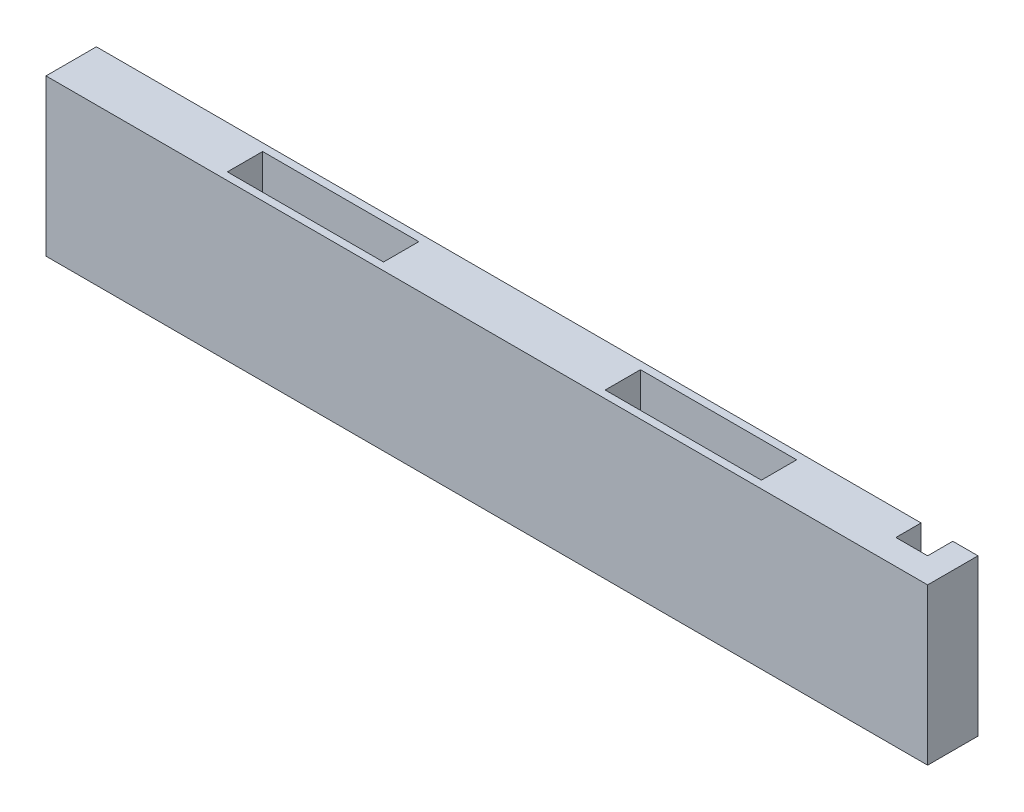
from build123d import *

# Parameters (mm, degrees)
ESBO_O1_W                = 175
ESBO_O1_H                = 31
RESSALTO_EXTRUS_O1_DEPTH = 10
ESBO_O2_W                = 31
ESBO_O2_H                = 7
CORTE_EXTRUS_O1_DEPTH    = 10.5
ESBO_O3_W                = 31
ESBO_O3_H                = 7
CORTE_EXTRUS_O2_DEPTH    = 10.5
ESBO_O6_W                = 6.3
ESBO_O6_H                = 31
CORTE_EXTRUS_O5_DEPTH    = 5
ESBO_O5_R                = 1.5
CORTE_EXTRUS_O4_DEPTH    = 8
CORTE_EXTRUS_O6_DEPTH    = 163.7


with BuildPart() as part:
    # Esboço1 → Ressalto-extrusão1 (new body)
    with BuildSketch(Plane.XY):
        Rectangle(ESBO_O1_W, ESBO_O1_H)
    extrude(amount=RESSALTO_EXTRUS_O1_DEPTH)

    # Esboço2 → Corte-extrusão1 (cut)
    with BuildSketch(Plane(origin=(0, 15.5, 0), x_dir=(1, 0, 0), z_dir=(0, 1, 0))):
        with Locations((-37.5, -5)):
            Rectangle(ESBO_O2_W, ESBO_O2_H)
        with Locations((37.5, -5)):
            Rectangle(ESBO_O2_W, ESBO_O2_H)
    extrude(amount=-CORTE_EXTRUS_O1_DEPTH, mode=Mode.SUBTRACT)

    # Esboço3 → Corte-extrusão2 (cut)
    with BuildSketch(Plane.XZ.offset(15.5)):
        with Locations((-37.5, 5)):
            Rectangle(ESBO_O3_W, ESBO_O3_H)
        with Locations((37.5, 5)):
            Rectangle(ESBO_O3_W, ESBO_O3_H)
    extrude(amount=-CORTE_EXTRUS_O2_DEPTH, mode=Mode.SUBTRACT)

    # Esboço6 → Corte-extrusão5 (cut)
    with BuildSketch(Plane(origin=(0, 0, 0), x_dir=(-1, 0, 0), z_dir=(0, 0, -1))):
        with Locations((-79.35, 0)):
            Rectangle(ESBO_O6_W, ESBO_O6_H)
    extrude(amount=-CORTE_EXTRUS_O5_DEPTH, mode=Mode.SUBTRACT)

    # Esboço5 → Corte-extrusão4 (cut)
    with BuildSketch(Plane.ZY.offset(87.5)):
        with Locations((5, 10.5)):
            Circle(ESBO_O5_R)
        with Locations((5, -10.5)):
            Circle(ESBO_O5_R)
    extrude(amount=-CORTE_EXTRUS_O4_DEPTH, mode=Mode.SUBTRACT)

    # Esboço4 → Corte-extrusão6 (cut)
    with BuildSketch(Plane.ZY.offset(87.5)):
        Polygon((0, 2.5), (7.140740034, -2.5), (0, -2.5), align=None)
    extrude(amount=-CORTE_EXTRUS_O6_DEPTH, mode=Mode.SUBTRACT)


solid = part.part
